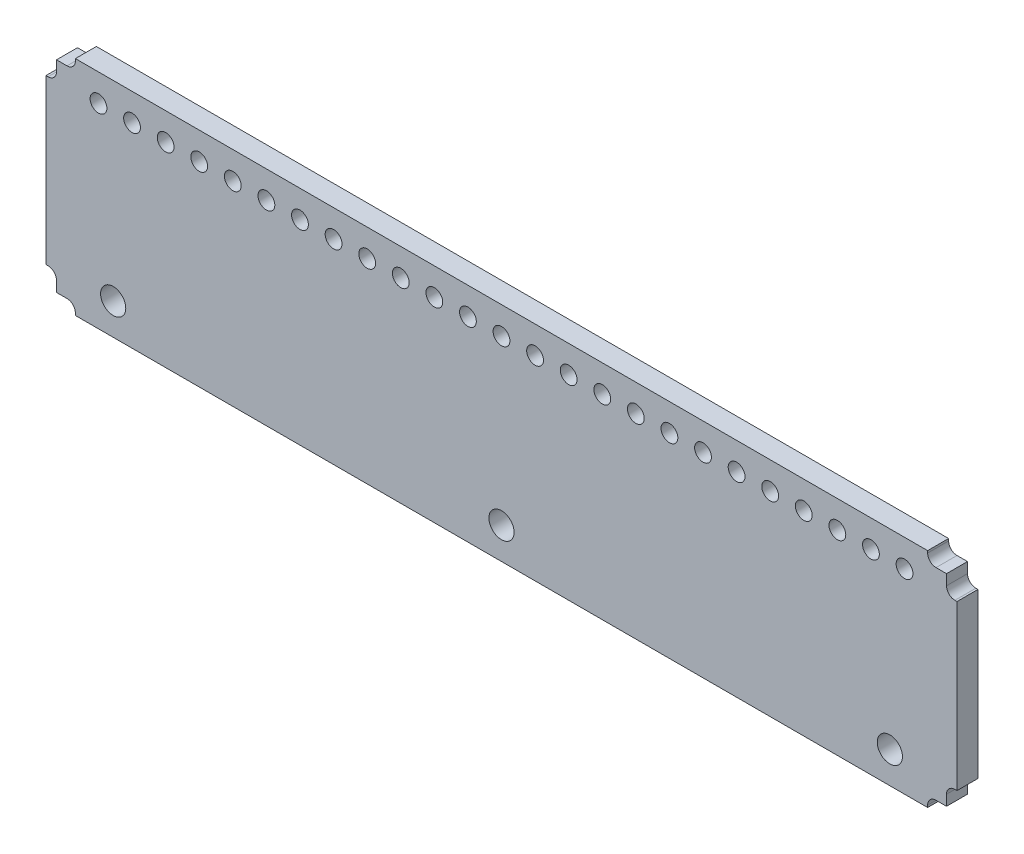
from build123d import *

# Parameters (mm, degrees)
SKETCH1_W               = 673.1
SKETCH1_H               = 152.4
BOSS_EXTRUDE1_DEPTH     = 7.9375
SKETCH2_W               = 7.9375
SKETCH2_H               = 123.825
SKETCH2_W_2             = 644.525
SKETCH2_H_2             = 7.9375
BOSS_EXTRUDE2_DEPTH     = 15.875
FILLET1_R               = 6.35
SKETCH3_R               = 9.525
SKETCH3_R_2             = 6.35
CUT_EXTRUDE1_DEPTH      = 1
CUT_EXTRUDE1_DEPTH_BACK = 16.875


with BuildPart() as part:
    # Sketch1 → Boss-Extrude1 (new body, symmetric)
    with BuildSketch(Plane.XY):
        Rectangle(SKETCH1_W, SKETCH1_H)
    extrude(amount=BOSS_EXTRUDE1_DEPTH, both=True)

    # Sketch2 → Boss-Extrude2 (add)
    with BuildSketch(Plane.XY.offset(7.9375)):
        with Locations((-340.51875, 0)):
            Rectangle(SKETCH2_W, SKETCH2_H)
        with Locations((0, 80.16875)):
            Rectangle(SKETCH2_W_2, SKETCH2_H_2)
        with Locations((0, -80.16875)):
            Rectangle(SKETCH2_W_2, SKETCH2_H_2)
        with Locations((340.51875, 0)):
            Rectangle(SKETCH2_W, SKETCH2_H)
    extrude(amount=-BOSS_EXTRUDE2_DEPTH)

    # Fillet1
    fillet1_edges = [part.edges().sort_by_distance(p)[0] for p in [
        (-336.55, -61.9125, 0),
        (-336.55, 61.9125, 0),
        (322.2625, 76.2, 0),
        (-322.2625, 76.2, 0),
        (322.2625, -76.2, 0),
        (-322.2625, -76.2, 0),
        (336.55, 61.9125, 0),
        (336.55, -61.9125, 0),
    ]]
    fillet(fillet1_edges, radius=FILLET1_R)

    # Sketch3 → Cut-Extrude1 (cut, two sides)
    with BuildSketch(Plane.XY.offset(7.9375)) as cut_extrude1_sk:
        with Locations((0, -60.325)):
            Circle(SKETCH3_R)
        with Locations((0, 63.5)):
            Circle(SKETCH3_R_2)
        with Locations((25.4, 63.5)):
            Circle(SKETCH3_R_2)
        with Locations((50.8, 63.5)):
            Circle(SKETCH3_R_2)
        with Locations((76.2, 63.5)):
            Circle(SKETCH3_R_2)
        with Locations((101.6, 63.5)):
            Circle(SKETCH3_R_2)
        with Locations((127, 63.5)):
            Circle(SKETCH3_R_2)
        with Locations((152.4, 63.5)):
            Circle(SKETCH3_R_2)
        with Locations((177.8, 63.5)):
            Circle(SKETCH3_R_2)
        with Locations((203.2, 63.5)):
            Circle(SKETCH3_R_2)
        with Locations((228.6, 63.5)):
            Circle(SKETCH3_R_2)
        with Locations((254, 63.5)):
            Circle(SKETCH3_R_2)
        with Locations((279.4, 63.5)):
            Circle(SKETCH3_R_2)
        with Locations((304.8, 63.5)):
            Circle(SKETCH3_R_2)
        with Locations((-25.4, 63.5)):
            Circle(SKETCH3_R_2)
        with Locations((-50.8, 63.5)):
            Circle(SKETCH3_R_2)
        with Locations((-76.2, 63.5)):
            Circle(SKETCH3_R_2)
        with Locations((-101.6, 63.5)):
            Circle(SKETCH3_R_2)
        with Locations((-127, 63.5)):
            Circle(SKETCH3_R_2)
        with Locations((-152.4, 63.5)):
            Circle(SKETCH3_R_2)
        with Locations((-177.8, 63.5)):
            Circle(SKETCH3_R_2)
        with Locations((-203.2, 63.5)):
            Circle(SKETCH3_R_2)
        with Locations((-228.6, 63.5)):
            Circle(SKETCH3_R_2)
        with Locations((-254, 63.5)):
            Circle(SKETCH3_R_2)
        with Locations((-279.4, 63.5)):
            Circle(SKETCH3_R_2)
        with Locations((-304.8, 63.5)):
            Circle(SKETCH3_R_2)
        with Locations((293.6875, -60.325)):
            Circle(SKETCH3_R)
        with Locations((-293.6875, -60.325)):
            Circle(SKETCH3_R)
    extrude(amount=CUT_EXTRUDE1_DEPTH, mode=Mode.SUBTRACT)
    extrude(cut_extrude1_sk.sketch, amount=-CUT_EXTRUDE1_DEPTH_BACK, mode=Mode.SUBTRACT)


solid = part.part
